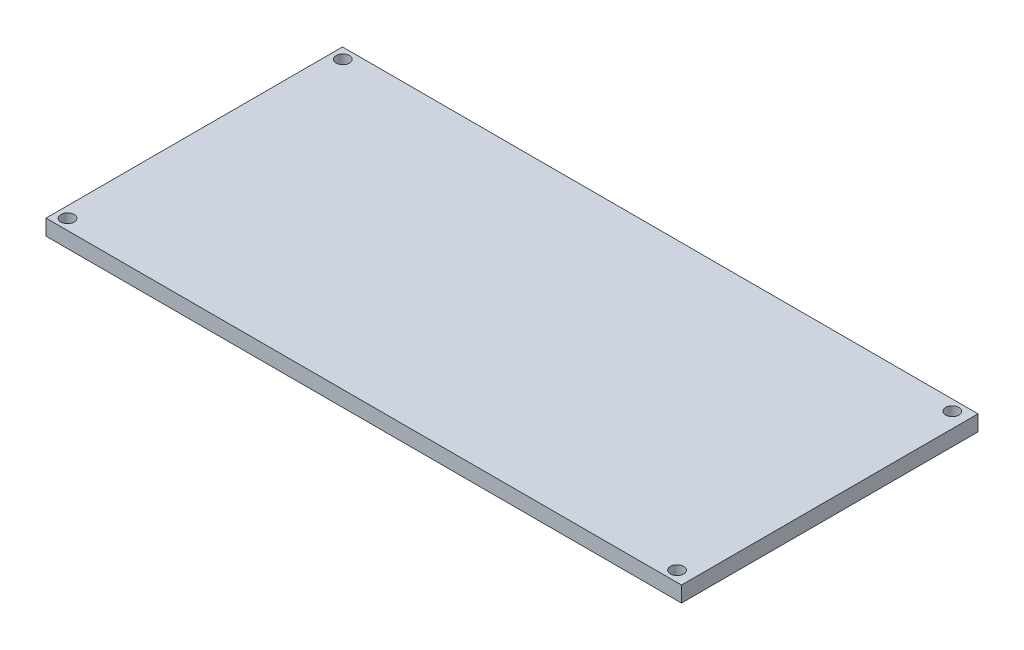
from build123d import *

# Parameters (mm, degrees)
SKETCH1_W           = 119.81
SKETCH1_H           = 55.9
BOSS_EXTRUDE1_DEPTH = 2.95
SKETCH2_R           = 1.25
CUT_EXTRUDE1_DEPTH  = 10


with BuildPart() as part:
    # Sketch1 → Boss-Extrude1 (new body)
    with BuildSketch(Plane(origin=(0, 0, 0), x_dir=(1, 0, 0), z_dir=(0, 1, 0))):
        with Locations((3.045, 0)):
            Rectangle(SKETCH1_W, SKETCH1_H)
    extrude(amount=BOSS_EXTRUDE1_DEPTH)

    # Sketch2 → Cut-Extrude1 (cut)
    with BuildSketch(Plane(origin=(0, 2.95, 0), x_dir=(1, 0, 0), z_dir=(0, 1, 0))):
        with Locations((-54.802113198, -25.95)):
            Circle(SKETCH2_R)
        with Locations((60.11, -25.95)):
            Circle(SKETCH2_R)
        with Locations((-54.802113198, 25.95)):
            Circle(SKETCH2_R)
        with Locations((60.107886802, 25.95)):
            Circle(SKETCH2_R)
    extrude(amount=-CUT_EXTRUDE1_DEPTH, mode=Mode.SUBTRACT)


solid = part.part
